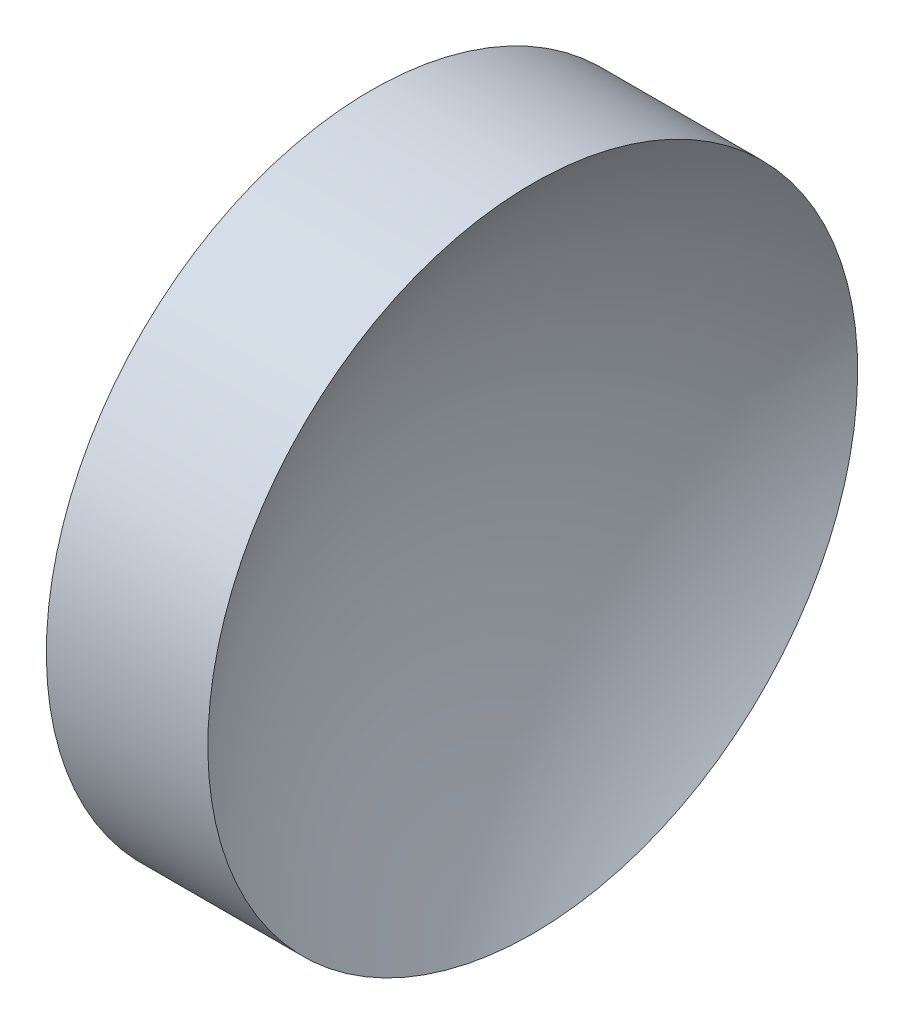
from build123d import *


with BuildPart() as part:
    # 草图1 → 旋转1 (revolve)
    with BuildSketch(Plane.XY, mode=Mode.PRIVATE) as revolve_1_sk:
        with BuildLine():
            Line((57.358190158, 32.578725913), (57.358190158, 45.078725913))
            Line((57.358190158, 45.078725913), (63.571301862, 45.078725913))
            ThreePointArc((63.571301862, 45.078725913), (60.43980158, 39.174182298), (59.358189641, 32.578725913))
            Line((59.358189641, 32.578725913), (57.358190158, 32.578725913))
        make_face()
    revolve(revolve_1_sk.sketch.rotate(Axis((55.007394624, 32.578725913, 0), (1, 0, 0)), 180), axis=Axis((55.007394624, 32.578725913, 0), (1, 0, 0)))  # turned: the seam where the file's is


solid = part.part
